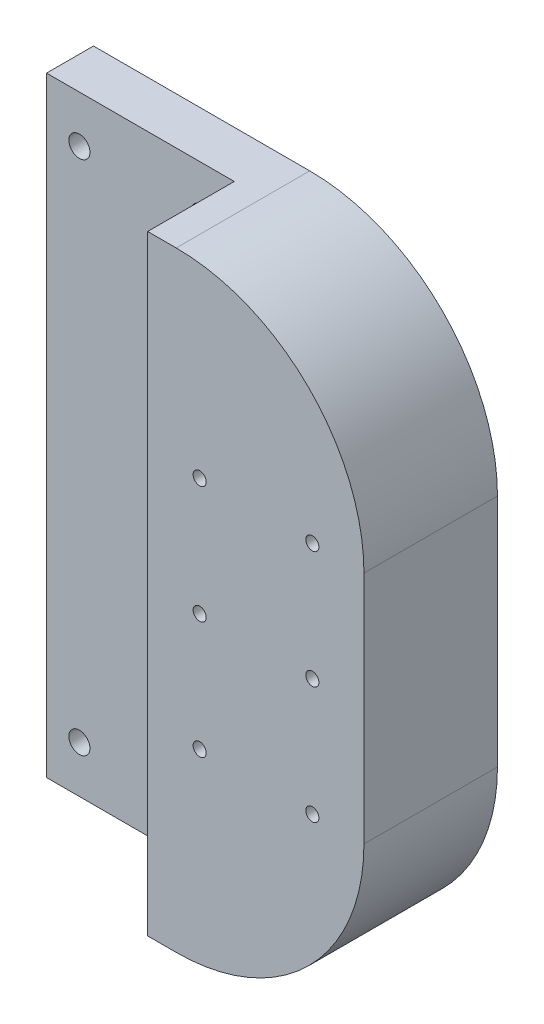
from build123d import *

# Parameters (mm, degrees)
SKETCH1_R           = 1.4
SKETCH1_R_2         = 2.25
BOSS_EXTRUDE1_DEPTH = 10
SKETCH1_3_R         = 1.4
BOSS_EXTRUDE2_DEPTH = 28.45


with BuildPart() as part:
    # Sketch1 → Boss-Extrude1 (new body)
    with BuildSketch(Plane.XY):
        with BuildLine():
            ThreePointArc((3.042, -65.000000484), (31.326271247, -53.284271732), (43.042, -25.000000484))
            Line((43.042, -25.000000484), (43.042, 25.000000484))
            ThreePointArc((43.042, 25.000000484), (31.326271247, 53.284271732), (3.042, 65.000000484))
            Line((3.042, 65.000000484), (-43.042, 65.000000484))
            Line((-43.042, 65.000000484), (-43.042, -65.000000484))
            Line((-43.042, -65.000000484), (3.042, -65.000000484))
        make_face()
        with Locations((8.041768895, -25.000000484)):
            Circle(SKETCH1_R, mode=Mode.SUBTRACT)
        with Locations((32.041768895, -25.000000484)):
            Circle(SKETCH1_R, mode=Mode.SUBTRACT)
        with Locations((8.041768895, 0)):
            Circle(SKETCH1_R, mode=Mode.SUBTRACT)
        with Locations((8.041768895, 25.000000484)):
            Circle(SKETCH1_R, mode=Mode.SUBTRACT)
        with Locations((32.041768895, 0)):
            Circle(SKETCH1_R, mode=Mode.SUBTRACT)
        with Locations((32.041768895, 25.000000484)):
            Circle(SKETCH1_R, mode=Mode.SUBTRACT)
        with Locations((-10.042, 55.000000484)):
            Circle(SKETCH1_R_2, mode=Mode.SUBTRACT)
        with Locations((-36.042, -54.999999516)):
            Circle(SKETCH1_R_2, mode=Mode.SUBTRACT)
        with Locations((-10.042, -54.999999516)):
            Circle(SKETCH1_R_2, mode=Mode.SUBTRACT)
        with Locations((-36.042, 55.000000484)):
            Circle(SKETCH1_R_2, mode=Mode.SUBTRACT)
    extrude(amount=BOSS_EXTRUDE1_DEPTH)

    # Sketch1_3 → Boss-Extrude2 (add)
    with BuildSketch(Plane.XY):
        with BuildLine():
            ThreePointArc((3.042, -65.000000484), (31.326271247, -53.284271732), (43.042, -25.000000484))
            Line((43.042, -25.000000484), (43.042, 25.000000484))
            ThreePointArc((43.042, 25.000000484), (31.326271247, 53.284271732), (3.042, 65.000000484))
            Line((3.042, 65.000000484), (-3.042, 65.000000484))
            Line((-3.042, 65.000000484), (-3.042, -65.000000484))
            Line((-3.042, -65.000000484), (3.042, -65.000000484))
        make_face()
        with Locations((8.041768895, -25.000000484)):
            Circle(SKETCH1_3_R, mode=Mode.SUBTRACT)
        with Locations((32.041768895, -25.000000484)):
            Circle(SKETCH1_3_R, mode=Mode.SUBTRACT)
        with Locations((8.041768895, 0)):
            Circle(SKETCH1_3_R, mode=Mode.SUBTRACT)
        with Locations((8.041768895, 25.000000484)):
            Circle(SKETCH1_3_R, mode=Mode.SUBTRACT)
        with Locations((32.041768895, 0)):
            Circle(SKETCH1_3_R, mode=Mode.SUBTRACT)
        with Locations((32.041768895, 25.000000484)):
            Circle(SKETCH1_3_R, mode=Mode.SUBTRACT)
    extrude(amount=BOSS_EXTRUDE2_DEPTH)


solid = part.part
